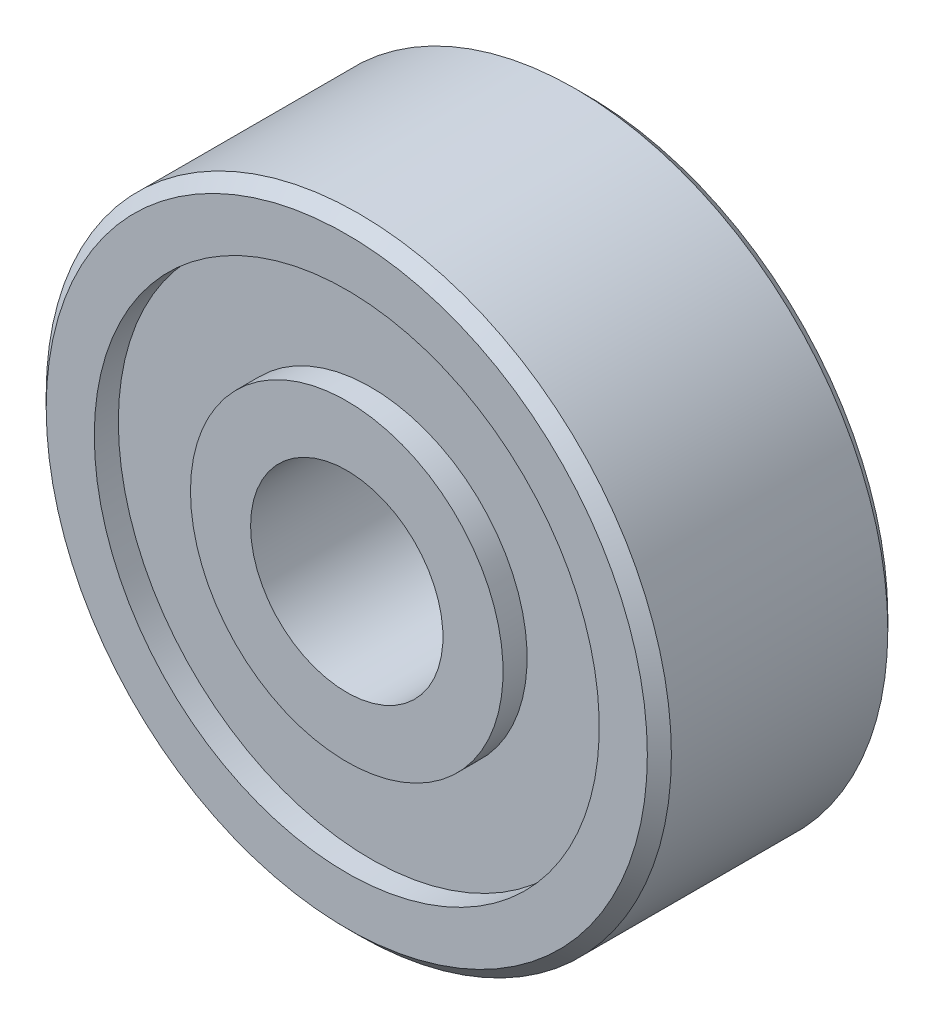
from build123d import *


with BuildPart() as part:
    # Sketch1 → Revolve1 (revolve)
    with BuildSketch(Plane.XZ):
        Polygon((6.5, 2.25), (6.25, 2.5), (5.25, 2.5), (5.25, 2), (3.25, 2), (3.25, 2.5), (2, 2.5), (2, -2.5), (3.25, -2.5), (3.25, -2), (5.25, -2), (5.25, -2.5), (6.25, -2.5), (6.5, -2.25), align=None)
    revolve(axis=Axis((0, 0, 2.5), (0, 0, -1)))


solid = part.part
